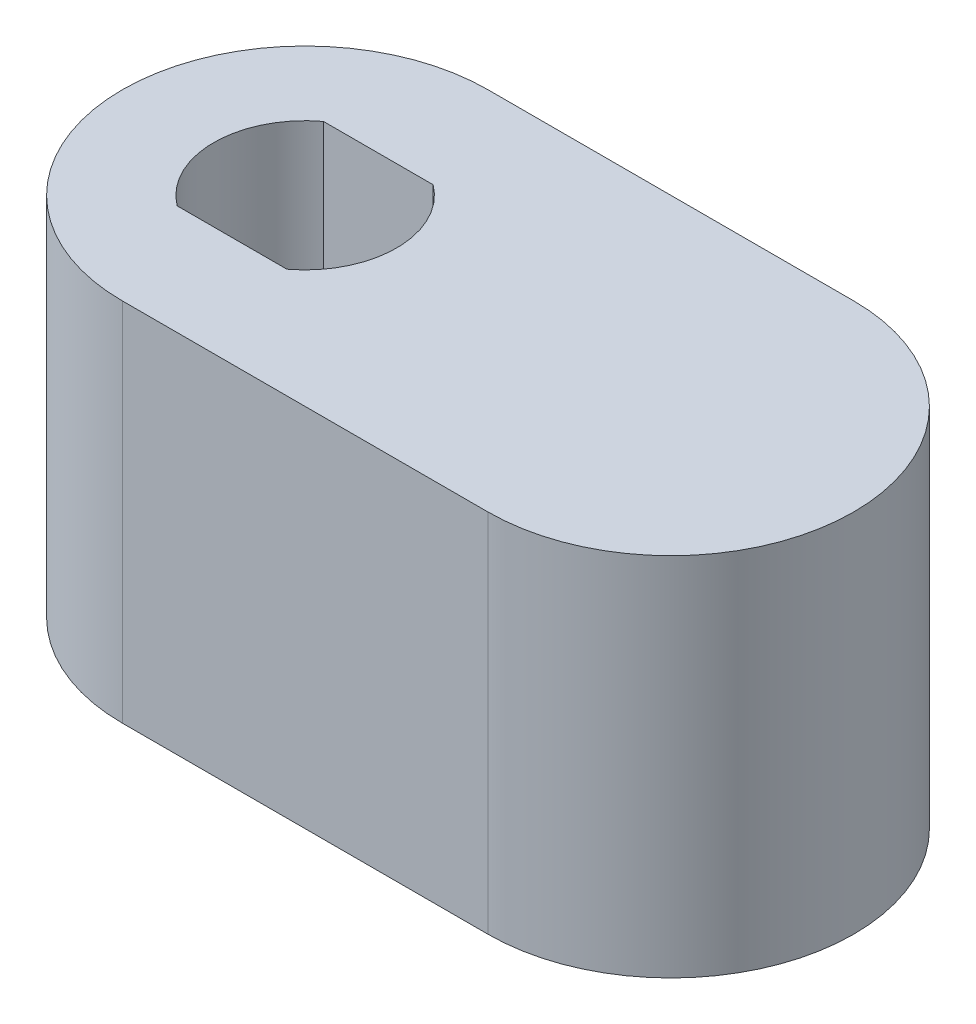
from build123d import *

# Parameters (mm, degrees)
EXTRUDE_1_DEPTH              = 10
CUT_EXTRUDE_1_DEPTH          = 4
HOLE_WIZARD_M3_1_D           = 3.4
HOLE_WIZARD_M3_1_DEPTH       = 8.1
HOLE_WIZARD_M3_1_CSINK_D     = 6.72
HOLE_WIZARD_M3_1_CSINK_ANGLE = 90
HOLE_WIZARD_M3_1_TIP         = 1.021463052
HOLE_WIZARD_1_D              = 4.15
HOLE_WIZARD_1_DEPTH          = 7.5


with BuildPart() as part:
    # 草图1 → 凸台-拉伸1 (new body)
    with BuildSketch(Plane(origin=(0, 0, 0), x_dir=(1, 0, 0), z_dir=(0, 1, 0))):
        with BuildLine():
            Line((0, 5), (10, 5))
            ThreePointArc((10, 5), (15, 0), (10, -5))
            Line((10, -5), (0, -5))
            ThreePointArc((0, -5), (-5, 0), (0, 5))
        make_face()
    extrude(amount=EXTRUDE_1_DEPTH)

    # 草图2 → 切除-拉伸1 (cut)
    with BuildSketch(Plane(origin=(0, 10, 0), x_dir=(1, 0, 0), z_dir=(0, 1, 0))):
        with BuildLine():
            Line((1.5, 2), (-1.5, 2))
            ThreePointArc((-1.5, 2), (-2.5, 0), (-1.5, -2))
            Line((-1.5, -2), (1.5, -2))
            ThreePointArc((1.5, -2), (2.236067977, -1.118033989), (2.5, 0))
            ThreePointArc((2.5, 0), (2.236067977, 1.118033989), (1.5, 2))
        make_face()
    extrude(amount=-CUT_EXTRUDE_1_DEPTH, mode=Mode.SUBTRACT)

    # M3 六角凹锥坑螺钉的锥形沉头孔1
    with Locations(Plane(origin=(0, 0, 0), x_dir=(-1, 0, 0), z_dir=(0, -1, 0))):
        with Locations((0, 0)):
            CounterSinkHole(HOLE_WIZARD_M3_1_D / 2, HOLE_WIZARD_M3_1_CSINK_D / 2, depth=HOLE_WIZARD_M3_1_DEPTH, counter_sink_angle=HOLE_WIZARD_M3_1_CSINK_ANGLE)
            with Locations((0, 0, -(HOLE_WIZARD_M3_1_DEPTH + HOLE_WIZARD_M3_1_TIP / 2))):  # 118° drill point
                Cone(0, HOLE_WIZARD_M3_1_D / 2, HOLE_WIZARD_M3_1_TIP, mode=Mode.SUBTRACT)

    # 孔1
    with Locations(Plane(origin=(0, 0, 0), x_dir=(-1, 0, 0), z_dir=(0, -1, 0))):
        with Locations((-10, 0)):
            Hole(HOLE_WIZARD_1_D / 2, depth=HOLE_WIZARD_1_DEPTH)


solid = part.part
